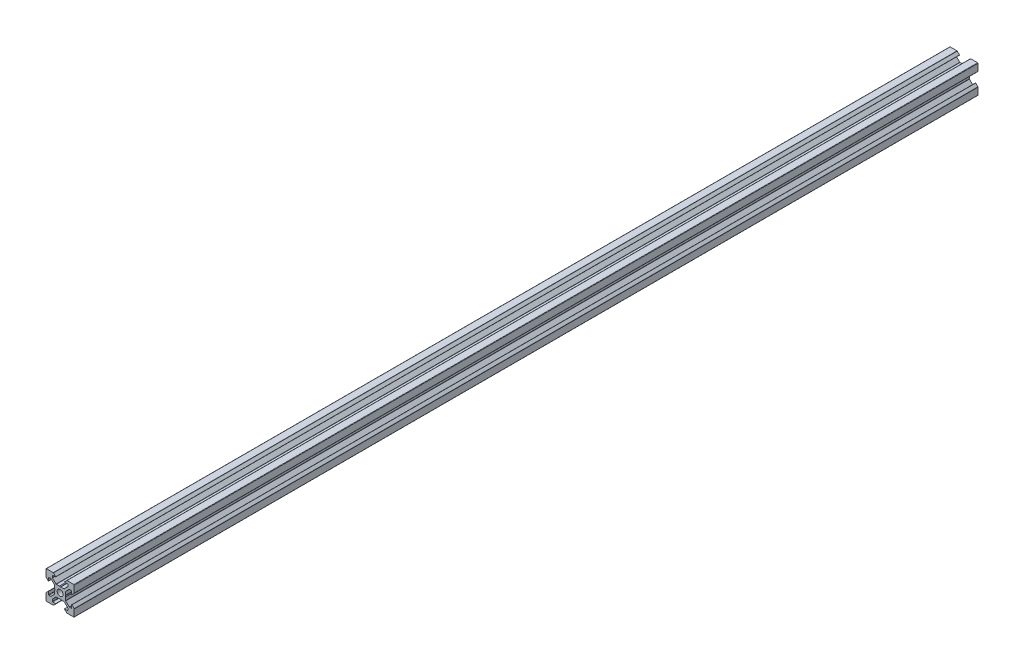
from build123d import *

# Parameters (mm, degrees)
BOSS_EXTRU_1_DEPTH = 640


with BuildPart() as part:
    # Esquisse1 → Boss.-Extru.1 (new body)
    with BuildSketch(Plane.XY):
        with BuildLine():
            Line((18.774857412, -2.895228684), (18.774857412, -4.894568513))
            ThreePointArc((18.774857412, -4.894568513), (18.686989447, -5.106700547), (18.474857412, -5.194568513))
            Line((18.474857412, -5.194568513), (17.259121481, -5.194568513))
            ThreePointArc((17.259121481, -5.194568513), (17.144316451, -5.171732372), (17.046989447, -5.106700547))
            Line((17.046989447, -5.106700547), (14.56338555, -2.62309665))
            ThreePointArc((14.56338555, -2.62309665), (14.498353724, -2.525769645), (14.475517584, -2.410964616))
            Line((14.475517584, -2.410964616), (14.475517584, -0.214843927))
            Line((14.475517584, -0.214843927), (14.175517584, 0.304771316))
            Line((14.175517584, 0.304771316), (14.475517584, 0.824386558))
            Line((14.475517584, 0.824386558), (14.475517584, 3.020507247))
            ThreePointArc((14.475517584, 3.020507247), (14.498353724, 3.135312277), (14.56338555, 3.232639281))
            Line((14.56338555, 3.232639281), (17.046989447, 5.716243178))
            ThreePointArc((17.046989447, 5.716243178), (17.144316451, 5.781275004), (17.259121481, 5.804111144))
            Line((17.259121481, 5.804111144), (18.474857412, 5.804111144))
            ThreePointArc((18.474857412, 5.804111144), (18.686989447, 5.716243178), (18.774857412, 5.504111144))
            Line((18.774857412, 5.504111144), (18.774857412, 3.504771316))
            ThreePointArc((18.774857412, 3.504771316), (18.836589069, 3.412383362), (18.94556809, 3.434060638))
            Line((18.94556809, 3.434060638), (20.486989447, 4.975481994))
            ThreePointArc((20.486989447, 4.975481994), (20.552021272, 5.072808998), (20.574857412, 5.187614028))
            Line((20.574857412, 5.187614028), (20.574857412, 10.004771316))
            ThreePointArc((20.574857412, 10.004771316), (20.486989447, 10.21690335), (20.274857412, 10.304771316))
            Line((20.274857412, 10.304771316), (15.457700125, 10.304771316))
            ThreePointArc((15.457700125, 10.304771316), (15.342895095, 10.281935175), (15.24556809, 10.21690335))
            Line((15.24556809, 10.21690335), (13.704146734, 8.675481994))
            ThreePointArc((13.704146734, 8.675481994), (13.682469459, 8.566502972), (13.774857412, 8.504771316))
            Line((13.774857412, 8.504771316), (15.77419724, 8.504771316))
            ThreePointArc((15.77419724, 8.504771316), (15.986329275, 8.41690335), (16.07419724, 8.204771316))
            Line((16.07419724, 8.204771316), (16.07419724, 6.989035384))
            ThreePointArc((16.07419724, 6.989035384), (16.0513611, 6.874230355), (15.986329275, 6.77690335))
            Line((15.986329275, 6.77690335), (13.502725378, 4.293299453))
            ThreePointArc((13.502725378, 4.293299453), (13.405398373, 4.228267628), (13.290593344, 4.205431487))
            Line((13.290593344, 4.205431487), (11.094472654, 4.205431487))
            Line((11.094472654, 4.205431487), (10.574857412, 3.905431487))
            Line((10.574857412, 3.905431487), (10.05524217, 4.205431487))
            Line((10.05524217, 4.205431487), (7.859121481, 4.205431487))
            ThreePointArc((7.859121481, 4.205431487), (7.744316451, 4.228267628), (7.646989447, 4.293299453))
            Line((7.646989447, 4.293299453), (5.16338555, 6.77690335))
            ThreePointArc((5.16338555, 6.77690335), (5.098353724, 6.874230355), (5.075517584, 6.989035384))
            Line((5.075517584, 6.989035384), (5.075517584, 8.204771316))
            ThreePointArc((5.075517584, 8.204771316), (5.16338555, 8.41690335), (5.375517584, 8.504771316))
            Line((5.375517584, 8.504771316), (7.374857412, 8.504771316))
            ThreePointArc((7.374857412, 8.504771316), (7.467245365, 8.566502972), (7.44556809, 8.675481994))
            Line((7.44556809, 8.675481994), (5.904146734, 10.21690335))
            ThreePointArc((5.904146734, 10.21690335), (5.806819729, 10.281935175), (5.6920147, 10.304771316))
            Line((5.6920147, 10.304771316), (0.874857412, 10.304771316))
            ThreePointArc((0.874857412, 10.304771316), (0.662725378, 10.21690335), (0.574857412, 10.004771316))
            Line((0.574857412, 10.004771316), (0.574857412, 5.187614028))
            ThreePointArc((0.574857412, 5.187614028), (0.597693552, 5.072808998), (0.662725378, 4.975481994))
            Line((0.662725378, 4.975481994), (2.204146734, 3.434060638))
            ThreePointArc((2.204146734, 3.434060638), (2.313125755, 3.412383362), (2.374857412, 3.504771316))
            Line((2.374857412, 3.504771316), (2.374857412, 5.504111144))
            ThreePointArc((2.374857412, 5.504111144), (2.462725378, 5.716243178), (2.674857412, 5.804111144))
            Line((2.674857412, 5.804111144), (3.890593344, 5.804111144))
            ThreePointArc((3.890593344, 5.804111144), (4.005398373, 5.781275004), (4.102725378, 5.716243178))
            Line((4.102725378, 5.716243178), (6.586329275, 3.232639281))
            ThreePointArc((6.586329275, 3.232639281), (6.6513611, 3.135312277), (6.67419724, 3.020507247))
            Line((6.67419724, 3.020507247), (6.67419724, 0.824386558))
            Line((6.67419724, 0.824386558), (6.97419724, 0.304771316))
            Line((6.97419724, 0.304771316), (6.67419724, -0.214843927))
            Line((6.67419724, -0.214843927), (6.67419724, -2.410964616))
            ThreePointArc((6.67419724, -2.410964616), (6.6513611, -2.525769645), (6.586329275, -2.62309665))
            Line((6.586329275, -2.62309665), (4.102725378, -5.106700547))
            ThreePointArc((4.102725378, -5.106700547), (4.005398373, -5.171732372), (3.890593344, -5.194568513))
            Line((3.890593344, -5.194568513), (2.674857412, -5.194568513))
            ThreePointArc((2.674857412, -5.194568513), (2.462725378, -5.106700547), (2.374857412, -4.894568513))
            Line((2.374857412, -4.894568513), (2.374857412, -2.895228684))
            ThreePointArc((2.374857412, -2.895228684), (2.313125755, -2.802840731), (2.204146734, -2.824518006))
            Line((2.204146734, -2.824518006), (0.662725378, -4.365939362))
            ThreePointArc((0.662725378, -4.365939362), (0.597693552, -4.463266367), (0.574857412, -4.578071397))
            Line((0.574857412, -4.578071397), (0.574857412, -9.395228684))
            ThreePointArc((0.574857412, -9.395228684), (0.662725378, -9.607360719), (0.874857412, -9.695228684))
            Line((0.874857412, -9.695228684), (5.6920147, -9.695228684))
            ThreePointArc((5.6920147, -9.695228684), (5.806819729, -9.672392544), (5.904146734, -9.607360719))
            Line((5.904146734, -9.607360719), (7.44556809, -8.065939362))
            ThreePointArc((7.44556809, -8.065939362), (7.467245365, -7.956960341), (7.374857412, -7.895228684))
            Line((7.374857412, -7.895228684), (5.375517584, -7.895228684))
            ThreePointArc((5.375517584, -7.895228684), (5.16338555, -7.807360719), (5.075517584, -7.595228684))
            Line((5.075517584, -7.595228684), (5.075517584, -6.379492753))
            ThreePointArc((5.075517584, -6.379492753), (5.098353724, -6.264687723), (5.16338555, -6.167360719))
            Line((5.16338555, -6.167360719), (7.646989447, -3.683756822))
            ThreePointArc((7.646989447, -3.683756822), (7.744316451, -3.618724996), (7.859121481, -3.595888856))
            Line((7.859121481, -3.595888856), (10.05524217, -3.595888856))
            Line((10.05524217, -3.595888856), (10.574857412, -3.295888856))
            Line((10.574857412, -3.295888856), (11.094472654, -3.595888856))
            Line((11.094472654, -3.595888856), (13.290593344, -3.595888856))
            ThreePointArc((13.290593344, -3.595888856), (13.405398373, -3.618724996), (13.502725378, -3.683756822))
            Line((13.502725378, -3.683756822), (15.986329275, -6.167360719))
            ThreePointArc((15.986329275, -6.167360719), (16.0513611, -6.264687723), (16.07419724, -6.379492753))
            Line((16.07419724, -6.379492753), (16.07419724, -7.595228684))
            ThreePointArc((16.07419724, -7.595228684), (15.986329275, -7.807360719), (15.77419724, -7.895228684))
            Line((15.77419724, -7.895228684), (13.774857412, -7.895228684))
            ThreePointArc((13.774857412, -7.895228684), (13.682469459, -7.956960341), (13.704146734, -8.065939362))
            Line((13.704146734, -8.065939362), (15.24556809, -9.607360719))
            ThreePointArc((15.24556809, -9.607360719), (15.342895095, -9.672392544), (15.457700125, -9.695228684))
            Line((15.457700125, -9.695228684), (20.274857412, -9.695228684))
            ThreePointArc((20.274857412, -9.695228684), (20.486989447, -9.607360719), (20.574857412, -9.395228684))
            Line((20.574857412, -9.395228684), (20.574857412, -4.578071397))
            ThreePointArc((20.574857412, -4.578071397), (20.552021272, -4.463266367), (20.486989447, -4.365939362))
            Line((20.486989447, -4.365939362), (18.94556809, -2.824518006))
            ThreePointArc((18.94556809, -2.824518006), (18.836589069, -2.802840731), (18.774857412, -2.895228684))
        make_face()
        with BuildLine():
            ThreePointArc((10.574857412, -1.795228684), (12.059781653, -1.180152925), (12.674857412, 0.304771316))
            ThreePointArc((12.674857412, 0.304771316), (12.059781653, 1.789695556), (10.574857412, 2.404771316))
            ThreePointArc((10.574857412, 2.404771316), (9.089933172, 1.789695556), (8.474857412, 0.304771316))
            ThreePointArc((8.474857412, 0.304771316), (9.089933172, -1.180152925), (10.574857412, -1.795228684))
        make_face(mode=Mode.SUBTRACT)
    extrude(amount=BOSS_EXTRU_1_DEPTH)


solid = part.part
